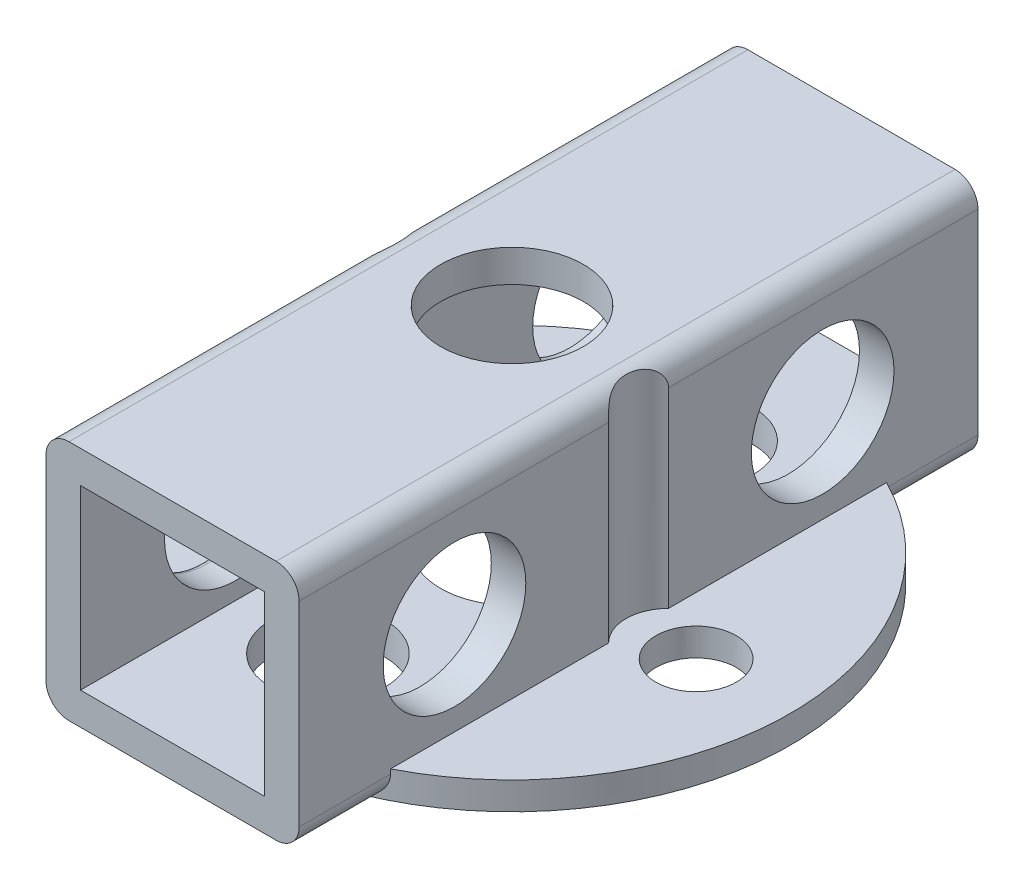
from build123d import *

# Parameters (mm, degrees)
SKETCH1_W                           = 11
SKETCH1_H                           = 29.5
BOSS_EXTRUDE1_DEPTH                 = 10.5
BOSS_EXTRUDE2_DEPTH                 = 1.2
CUT_EXTRUDE1_DEPTH                  = 9.3
BOSS_EXTRUDE3_DEPTH                 = 1.2
CUT_EXTRUDE2_DEPTH                  = 9.3
SKETCH6_W                           = 8
SKETCH6_H                           = 7.7
CUT_EXTRUDE3_DEPTH                  = 30.5
F_5_0_5_DIAMETER_HOLE1_D            = 5
F_5_0_5_DIAMETER_HOLE1_DEPTH        = 1.4
F_5_0_5_DIAMETER_HOLE2_D            = 5
F_5_0_5_DIAMETER_HOLE2_DEPTH        = 1.4
SKETCH11_W                          = 1.6
SKETCH11_H                          = 1
SKETCH12_W                          = 1.6
SKETCH12_H                          = 1
SKETCH13_W                          = 3.1
SKETCH13_H                          = 1.4
SKETCH15_W                          = 1.75
SKETCH15_H                          = 1.2
F_3_5_3_5_DIAMETER_HOLE1_AT_2_COUNT = 2
F_3_5_3_5_DIAMETER_HOLE1_AT_2_PITCH = 16
SKETCH17_W                          = 3.1
SKETCH17_H                          = 1.5
F_6_2_6_2_DIAMETER_HOLE2_AT_2_COUNT = 2
F_6_2_6_2_DIAMETER_HOLE2_AT_2_PITCH = 16
SKETCH19_W                          = 3.1
SKETCH19_H                          = 1.5
F_6_2_6_2_DIAMETER_HOLE3_AT_2_COUNT = 2
F_6_2_6_2_DIAMETER_HOLE3_AT_2_PITCH = 16
SKETCH21_W                          = 3.1
SKETCH21_H                          = 1.4
FILLET1_R                           = 1
FILLET3_R                           = 0.25


with BuildPart() as part:
    # Sketch1 → Boss-Extrude1 (new body)
    with BuildSketch(Plane.XZ):
        Rectangle(SKETCH1_W, SKETCH1_H)
    extrude(amount=-BOSS_EXTRUDE1_DEPTH)

    # Sketch2 → Boss-Extrude2 (add)
    with BuildSketch(Plane.XZ):
        with BuildLine():
            Line((-5.5, -10.777754868), (-5.5, 10.777754868))
            ThreePointArc((-5.5, 10.777754868), (-12.1, 0), (-5.5, -10.777754868))
        make_face()
    extrude(amount=-BOSS_EXTRUDE2_DEPTH)

    # Sketch3 → Cut-Extrude1 (cut)
    with BuildSketch(Plane(origin=(0, 10.5, 0), x_dir=(-1, 0, 0), z_dir=(0, 1, 0))):
        with BuildLine():
            Line((5.5, -1.302152065), (5.5, 1.302152065))
            ThreePointArc((5.5, 1.302152065), (4.96, 0), (5.5, -1.302152065))
        make_face()
    extrude(amount=-CUT_EXTRUDE1_DEPTH, mode=Mode.SUBTRACT)

    # Sketch4 → Boss-Extrude3 (add)
    with BuildSketch(Plane.XZ):
        with BuildLine():
            Line((5.5, 10.777754868), (5.5, -10.777754868))
            ThreePointArc((5.5, -10.777754868), (12.1, 0), (5.5, 10.777754868))
        make_face()
    extrude(amount=-BOSS_EXTRUDE3_DEPTH)

    # Sketch5 → Cut-Extrude2 (cut)
    with BuildSketch(Plane(origin=(0, 10.5, 0), x_dir=(-1, 0, 0), z_dir=(0, 1, 0))):
        with BuildLine():
            Line((-5.5, 1.302152065), (-5.5, -1.302152065))
            ThreePointArc((-5.5, -1.302152065), (-4.96, 0), (-5.5, 1.302152065))
        make_face()
    extrude(amount=-CUT_EXTRUDE2_DEPTH, mode=Mode.SUBTRACT)

    # Sketch6 → Cut-Extrude3 (cut, through all)
    with BuildSketch(Plane.XY.offset(14.75)):
        with Locations((0, 5.25)):
            Rectangle(SKETCH6_W, SKETCH6_H)
    extrude(amount=-CUT_EXTRUDE3_DEPTH, mode=Mode.SUBTRACT)

    # Ø5.0 (5) Diameter Hole1
    with Locations(Plane(origin=(0, 0, 0), x_dir=(-1, 0, 0), z_dir=(0, -1, 0))):
        with Locations((0, -8)):
            Hole(F_5_0_5_DIAMETER_HOLE1_D / 2, depth=F_5_0_5_DIAMETER_HOLE1_DEPTH)

    # Ø5.0 (5) Diameter Hole2
    with Locations(Plane(origin=(0, 0, 0), x_dir=(-1, 0, 0), z_dir=(0, -1, 0))):
        with Locations((0, 8)):
            Hole(F_5_0_5_DIAMETER_HOLE2_D / 2, depth=F_5_0_5_DIAMETER_HOLE2_DEPTH)

    # Sketch13 → Ø6.2 (6.2) Diameter Hole1 (revolve, cut)
    with BuildSketch(Plane(origin=(0, 0, 0), x_dir=(0, 0, -1), z_dir=(1, 0, 0))):
        with Locations((1.55, 0.7)):
            Rectangle(SKETCH13_W, SKETCH13_H)
    revolve(axis=Axis((0, -6.35, 0), (0, 1, 0)), mode=Mode.SUBTRACT)

    # Sketch15 → Ø3.5 (3.5) Diameter Hole1 (revolve, cut)
    with BuildSketch(Plane(origin=(8, 1.2, 0), x_dir=(0, 0, 1), z_dir=(1, 0, 0))):
        with Locations((0.875, 0.6)):
            Rectangle(SKETCH15_W, SKETCH15_H)
    f_3_5_3_5_diameter_hole1 = revolve(axis=Axis((8, 7.55, 0), (0, -1, 0)), mode=Mode.SUBTRACT)

    # Ø3.5 (3.5) Diameter Hole1 at 2: Ø3.5 (3.5) Diameter Hole1 ×2
    with Locations(*[(-i * F_3_5_3_5_DIAMETER_HOLE1_AT_2_PITCH, 0, 0) for i in range(1, F_3_5_3_5_DIAMETER_HOLE1_AT_2_COUNT)]):
        add(f_3_5_3_5_diameter_hole1, mode=Mode.SUBTRACT)

    # Sketch17 → Ø6.2 (6.2) Diameter Hole2 (revolve, cut)
    with BuildSketch(Plane(origin=(5.5, 5.25, 8), x_dir=(0, 0, -1), z_dir=(0, 1, 0))):
        with Locations((1.55, 0.75)):
            Rectangle(SKETCH17_W, SKETCH17_H)
    f_6_2_6_2_diameter_hole2 = revolve(axis=Axis((11.85, 5.25, 8), (-1, 0, 0)), mode=Mode.SUBTRACT)

    # Ø6.2 (6.2) Diameter Hole2 at 2: Ø6.2 (6.2) Diameter Hole2 ×2
    with Locations(*[(0, 0, -i * F_6_2_6_2_DIAMETER_HOLE2_AT_2_PITCH) for i in range(1, F_6_2_6_2_DIAMETER_HOLE2_AT_2_COUNT)]):
        add(f_6_2_6_2_diameter_hole2, mode=Mode.SUBTRACT)

    # Sketch19 → Ø6.2 (6.2) Diameter Hole3 (revolve, cut)
    with BuildSketch(Plane(origin=(-5.5, 5.25, 8), x_dir=(0, 0, 1), z_dir=(0, 1, 0))):
        with Locations((1.55, 0.75)):
            Rectangle(SKETCH19_W, SKETCH19_H)
    f_6_2_6_2_diameter_hole3 = revolve(axis=Axis((-11.85, 5.25, 8), (1, 0, 0)), mode=Mode.SUBTRACT)

    # Ø6.2 (6.2) Diameter Hole3 at 2: Ø6.2 (6.2) Diameter Hole3 ×2
    with Locations(*[(0, 0, -i * F_6_2_6_2_DIAMETER_HOLE3_AT_2_PITCH) for i in range(1, F_6_2_6_2_DIAMETER_HOLE3_AT_2_COUNT)]):
        add(f_6_2_6_2_diameter_hole3, mode=Mode.SUBTRACT)

    # Sketch21 → Ø6.2 (6.2) Diameter Hole4 (revolve, cut)
    with BuildSketch(Plane(origin=(0, 10.5, 0), x_dir=(0, 0, 1), z_dir=(1, 0, 0))):
        with Locations((1.55, 0.7)):
            Rectangle(SKETCH21_W, SKETCH21_H)
    revolve(axis=Axis((0, 16.85, 0), (0, -1, 0)), mode=Mode.SUBTRACT)

    # Fillet1
    fillet1_edges = [part.edges().sort_by_distance(p)[0] for p in [
        (5.5, 0, -12.763877434),
        (-5.5, 0, 12.763877434),
        (-5.5, 0, -12.763877434),
        (5.5, 10.5, 8.026076032),
        (5.5, 0, 12.763877434),
        (-5.5, 10.5, -8.026076032),
    ]]
    fillet(fillet1_edges, radius=FILLET1_R)

    # Fillet3
    fillet3_edges = [part.edges().sort_by_distance(p)[0] for p in [
        (-5.5, 5.25, 4.9),
    ]]
    fillet(fillet3_edges, radius=FILLET3_R)


with BuildPart() as body_2:
    # Sketch11 → Revolve1 (revolve)
    with BuildSketch(Plane(origin=(0, 0, -8), x_dir=(-1, 0, 0), z_dir=(0, 0, -1))):
        with Locations((-0.8, -0.25)):
            Rectangle(SKETCH11_W, SKETCH11_H)
    revolve(axis=Axis((0, -0.75, -8), (0, 1, 0)))


with BuildPart() as body_3:
    # Sketch12 → Revolve2 (revolve)
    with BuildSketch(Plane(origin=(0, 0, 8), x_dir=(-1, 0, 0), z_dir=(0, 0, -1))):
        with Locations((-0.8, -0.25)):
            Rectangle(SKETCH12_W, SKETCH12_H)
    revolve(axis=Axis((0, -0.75, 8), (0, 1, 0)))


solid = Compound([part.part, body_2.part, body_3.part])
